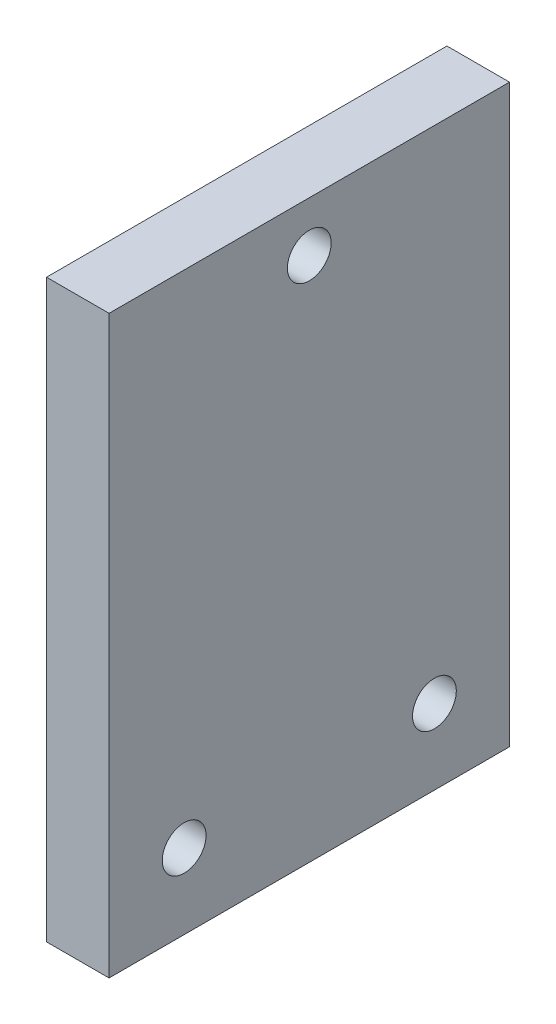
from build123d import *

# Parameters (mm, degrees)
SKETCH1_W           = 55
SKETCH1_H           = 32
BOSS_EXTRUDE1_DEPTH = 46
SKETCH2_W           = 45
SKETCH2_H           = 32
CUT_EXTRUDE1_DEPTH  = 45
SKETCH3_R           = 1.75
CUT_EXTRUDE2_DEPTH  = 47
SKETCH4_R           = 1.75
CUT_EXTRUDE3_DEPTH  = 56
SKETCH5_W           = 1.1
SKETCH5_H           = 35
CUT_EXTRUDE4_DEPTH  = 1.2
SKETCH7_W           = 32
SKETCH7_H           = 46
CUT_EXTRUDE5_DEPTH  = 50


with BuildPart() as part:
    # Sketch1 → Boss-Extrude1 (new body)
    with BuildSketch(Plane(origin=(0, 0, 0), x_dir=(1, 0, 0), z_dir=(0, 1, 0))):
        with Locations((27.5, 16)):
            Rectangle(SKETCH1_W, SKETCH1_H)
    extrude(amount=BOSS_EXTRUDE1_DEPTH)

    # Sketch2 → Cut-Extrude1 (cut)
    with BuildSketch(Plane.XZ):
        with Locations((27.5, -16)):
            Rectangle(SKETCH2_W, SKETCH2_H)
    extrude(amount=-CUT_EXTRUDE1_DEPTH, mode=Mode.SUBTRACT)

    # Sketch3 → Cut-Extrude2 (cut, through all)
    with BuildSketch(Plane(origin=(0, 46, 0), x_dir=(1, 0, 0), z_dir=(0, 1, 0))):
        with Locations((43.5, 26)):
            Circle(SKETCH3_R)
        with Locations((43.5, 6)):
            Circle(SKETCH3_R)
        with Locations((11.5, 26)):
            Circle(SKETCH3_R)
        with Locations((11.5, 6)):
            Circle(SKETCH3_R)
    extrude(amount=-CUT_EXTRUDE2_DEPTH, mode=Mode.SUBTRACT)

    # Sketch4 → Cut-Extrude3 (cut, through all)
    with BuildSketch(Plane(origin=(55, 0, 0), x_dir=(0, 0, -1), z_dir=(1, 0, 0))):
        with Locations((6, 6)):
            Circle(SKETCH4_R)
        with Locations((26, 6)):
            Circle(SKETCH4_R)
        with Locations((16, 42)):
            Circle(SKETCH4_R)
    extrude(amount=-CUT_EXTRUDE3_DEPTH, mode=Mode.SUBTRACT)

    # Sketch5 → Cut-Extrude4 (cut)
    with BuildSketch(Plane.ZY.offset(-50)):
        with Locations((-29.45, 27.5)):
            Rectangle(SKETCH5_W, SKETCH5_H)
        with Locations((-31.45, 27.5)):
            Rectangle(SKETCH5_W, SKETCH5_H)
        with Locations((-27.45, 27.5)):
            Rectangle(SKETCH5_W, SKETCH5_H)
        with Locations((-25.45, 27.5)):
            Rectangle(SKETCH5_W, SKETCH5_H)
        with Locations((-23.45, 27.5)):
            Rectangle(SKETCH5_W, SKETCH5_H)
        with Locations((-21.45, 27.5)):
            Rectangle(SKETCH5_W, SKETCH5_H)
        with Locations((-19.45, 27.5)):
            Rectangle(SKETCH5_W, SKETCH5_H)
        with Locations((-17.45, 27.5)):
            Rectangle(SKETCH5_W, SKETCH5_H)
        with Locations((-15.45, 27.5)):
            Rectangle(SKETCH5_W, SKETCH5_H)
        with Locations((-13.45, 27.5)):
            Rectangle(SKETCH5_W, SKETCH5_H)
        with Locations((-11.45, 27.5)):
            Rectangle(SKETCH5_W, SKETCH5_H)
        with Locations((-9.45, 27.5)):
            Rectangle(SKETCH5_W, SKETCH5_H)
        with Locations((-7.45, 27.5)):
            Rectangle(SKETCH5_W, SKETCH5_H)
        with Locations((-5.45, 27.5)):
            Rectangle(SKETCH5_W, SKETCH5_H)
        with Locations((-3.45, 27.5)):
            Rectangle(SKETCH5_W, SKETCH5_H)
        with Locations((-1.45, 27.5)):
            Rectangle(SKETCH5_W, SKETCH5_H)
        with Locations((0.55, 27.5)):
            Rectangle(SKETCH5_W, SKETCH5_H)
    extrude(amount=-CUT_EXTRUDE4_DEPTH, mode=Mode.SUBTRACT)

    # Sketch7 → Cut-Extrude5 (cut)
    with BuildSketch(Plane.ZY):
        with Locations((-16, 23)):
            Rectangle(SKETCH7_W, SKETCH7_H)
    extrude(amount=-CUT_EXTRUDE5_DEPTH, mode=Mode.SUBTRACT)


solid = part.part
